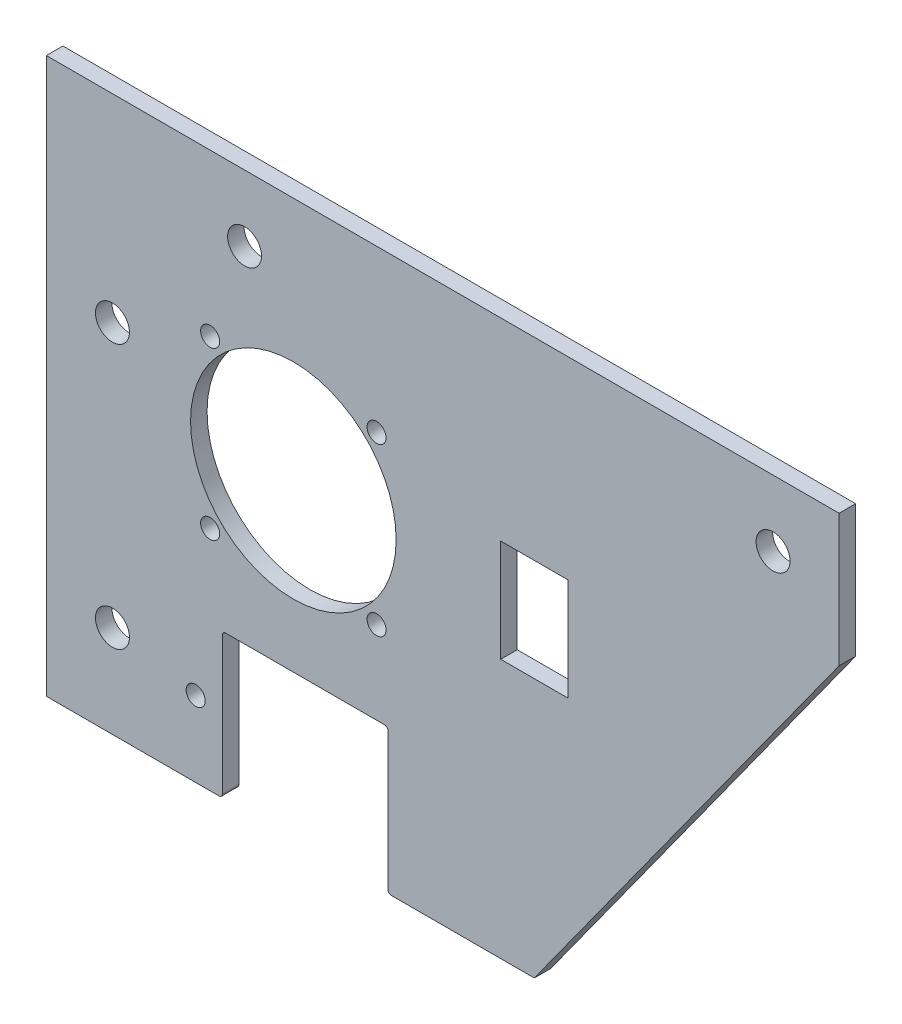
from build123d import *

# Parameters (mm, degrees)
SKETCH2_R               = 19.762
SKETCH2_W               = 12.9032
SKETCH2_H               = 19.685
BOSS_EXTRUDE1_DEPTH     = 3.175
F_6_CLEARANCE_HOLE1_D   = 3.6576
FILLET1_R               = 0.635
F_1_4_CLEARANCE_HOLE1_D = 6.5278


with BuildPart() as part:
    # Sketch2 → Boss-Extrude1 (new body)
    with BuildSketch(Plane.XY):
        Polygon((105.5, 66.04), (-46.9, 66.04), (-46.9, -40.64), (-13.062, -40.64), (-13.062, -12.878), (18.762, -12.878), (18.762, -40.64), (46.9, -40.64), (105.5, 40.64), align=None)
        with Locations((0.58, 19.04)):
            Circle(SKETCH2_R, mode=Mode.SUBTRACT)
        with Locations((46.9, 19.04)):
            Rectangle(SKETCH2_W, SKETCH2_H, mode=Mode.SUBTRACT)
    extrude(amount=BOSS_EXTRUDE1_DEPTH)

    # #6 Clearance Hole1 (through all)
    with Locations(Plane.XY.offset(3.175)):
        with Locations((-15.42, 35.04), (16.58, 35.04), (16.58, 3.04), (-15.42, 3.04), (-18.198, -26.14)):
            Hole(F_6_CLEARANCE_HOLE1_D / 2)

    # Fillet1
    fillet1_edges = [part.edges().sort_by_distance(p)[0] for p in [
        (18.762, -40.64, 1.5875),
        (18.762, -12.878, 1.5875),
        (-13.062, -12.878, 1.5875),
        (-13.062, -40.64, 1.5875),
    ]]
    fillet(fillet1_edges, radius=FILLET1_R)

    # 1/4 Clearance Hole1 (through all)
    with Locations(Plane.XY.offset(3.175)):
        with Locations((-34.2, -22.86), (-8.8, 53.34), (92.8, 53.34), (-34.2, 27.94)):
            Hole(F_1_4_CLEARANCE_HOLE1_D / 2)


solid = part.part
